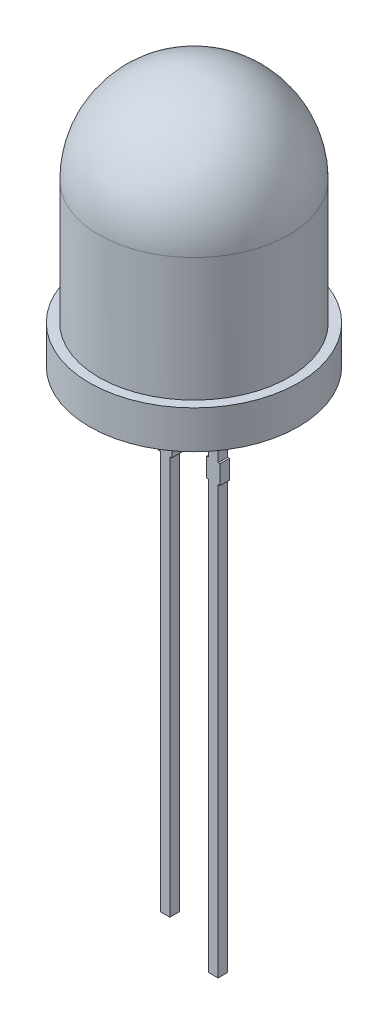
from build123d import *

# Parameters (mm, degrees)
SKETCH2_R          = 5.5
EXTRUDE2_DEPTH     = 2
SKETCH3_3_W        = 0.5
SKETCH3_3_H        = 3.5
SKETCH3_3_H_2      = 1
SKETCH3_3_H_3      = 21
SKETCH3_3_W_2      = 0.1
SKETCH3_3_H_4      = 22.5
EXTRUDE4_DEPTH     = 0.25
CUT_EXTRUDE1_DEPTH = 0.01


with BuildPart() as part:
    # Sketch2 → Extrude2 (new body)
    with BuildSketch(Plane(origin=(0, 0, 0), x_dir=(1, 0, 0), z_dir=(0, 1, 0))):
        with Locations(Location((0, 0, 0), (0, 0, 270))):  # turned: the seam where the file's is
            Circle(SKETCH2_R)
    extrude(amount=EXTRUDE2_DEPTH)

    # Sketch3 → Revolve1 (revolve)
    with BuildSketch(Plane.XY, mode=Mode.PRIVATE) as revolve1_sk:
        with BuildLine():
            Line((0, 13.5), (0, 2))
            Line((0, 2), (5, 2))
            Line((5, 2), (5, 8.5))
            ThreePointArc((5, 8.5), (3.535533906, 12.035533906), (0, 13.5))
        make_face()
    revolve(revolve1_sk.sketch.rotate(Axis((0, 2, 0), (0, 1, 0)), 180), axis=Axis((0, 2, 0), (0, 1, 0)))  # turned: the seam where the file's is

    # Sketch3_3 → Extrude4 (add, symmetric)
    with BuildSketch(Plane.XY):
        with Locations((-1.27, -1.75)):
            Rectangle(SKETCH3_3_W, SKETCH3_3_H)
        with Locations((-1.27, -4)):
            Rectangle(SKETCH3_3_W, SKETCH3_3_H_2)
        with Locations((-1.27, -15)):
            Rectangle(SKETCH3_3_W, SKETCH3_3_H_3)
        with Locations((-0.97, -4)):
            Rectangle(SKETCH3_3_W_2, SKETCH3_3_H_2)
        with Locations((-1.57, -4)):
            Rectangle(SKETCH3_3_W_2, SKETCH3_3_H_2)
        with Locations((1.27, -1.75)):
            Rectangle(SKETCH3_3_W, SKETCH3_3_H)
        with Locations((1.27, -4)):
            Rectangle(SKETCH3_3_W, SKETCH3_3_H_2)
        with Locations((0.97, -4)):
            Rectangle(SKETCH3_3_W_2, SKETCH3_3_H_2)
        with Locations((1.57, -4)):
            Rectangle(SKETCH3_3_W_2, SKETCH3_3_H_2)
        with Locations((1.27, -15.75)):
            Rectangle(SKETCH3_3_W, SKETCH3_3_H_4)
    extrude(amount=EXTRUDE4_DEPTH, both=True)

    # Sketch5 → Cut-Extrude1 (cut)
    with BuildSketch(Plane.XZ):
        Polygon((-0.506420788, 0.019460325), (-0.528175596, -0.053616598), (-0.544431606, -0.053616598), (-0.556661173, -0.002685107), (-0.570543384, -0.053616598), (-0.58670925, -0.053616598), (-0.608343865, 0.019460325), (-0.589593865, 0.019460325), (-0.578626317, -0.033364194), (-0.565555404, 0.019460325), (-0.547376317, 0.019460325), (-0.535958048, -0.033364194), (-0.525260933, 0.019460325), align=None)
        Polygon((-0.406420788, 0.019460325), (-0.428175596, -0.053616598), (-0.444431606, -0.053616598), (-0.456661173, -0.002685107), (-0.470543384, -0.053616598), (-0.48670925, -0.053616598), (-0.508343865, 0.019460325), (-0.489593865, 0.019460325), (-0.478626317, -0.033364194), (-0.465555404, 0.019460325), (-0.447376317, 0.019460325), (-0.435958048, -0.033364194), (-0.425260933, 0.019460325), align=None)
        Polygon((-0.306420788, 0.019460325), (-0.328175596, -0.053616598), (-0.344431606, -0.053616598), (-0.356661173, -0.002685107), (-0.370543384, -0.053616598), (-0.38670925, -0.053616598), (-0.408343865, 0.019460325), (-0.389593865, 0.019460325), (-0.378626317, -0.033364194), (-0.365555404, 0.019460325), (-0.347376317, 0.019460325), (-0.335958048, -0.033364194), (-0.325260933, 0.019460325), align=None)
        with BuildLine():
            add(Edge.make_bspline(
                [(-0.266036173, -0.041116598), (-0.266085656, -0.041823455), (-0.266188443, -0.043291736), (-0.266956737, -0.045436115), (-0.26809552, -0.047545152), (-0.269733004, -0.049465295), (-0.271830584, -0.051145185), (-0.274341711, -0.052524917), (-0.277281997, -0.053461887), (-0.27938031, -0.053564061), (-0.28045925, -0.053616598)],
                knots=[0, 0, 0, 0, 0.803957419, 1.669978378, 2.568830098, 3.52434643, 4.522321038, 5.61514242, 6.773720829, 8, 8, 8, 8], degree=3))
            add(Edge.make_bspline(
                [(-0.28045925, -0.053616598), (-0.281296472, -0.053573063), (-0.282975241, -0.053485769), (-0.285370285, -0.052698164), (-0.287544342, -0.051535025), (-0.289416473, -0.049985848), (-0.290875306, -0.048076689), (-0.292084891, -0.045979976), (-0.292823926, -0.043607544), (-0.292913819, -0.04195285), (-0.29295925, -0.041116598)],
                knots=[0, 0, 0, 0, 1.021956945, 2.049191568, 3.052757421, 4.027239216, 4.995768388, 5.977850542, 6.978043055, 8, 8, 8, 8], degree=3))
            add(Edge.make_bspline(
                [(-0.29295925, -0.041116598), (-0.292915955, -0.040279427), (-0.292830784, -0.038632504), (-0.29206897, -0.036286655), (-0.290922794, -0.034177935), (-0.289422618, -0.032310803), (-0.287583678, -0.030711261), (-0.285368094, -0.029583562), (-0.282982384, -0.028736766), (-0.281297833, -0.028656537), (-0.28045925, -0.028616598)],
                knots=[0, 0, 0, 0, 1.02256761, 2.011643391, 2.988402578, 3.947919371, 4.930894396, 5.945859716, 6.97743239, 8, 8, 8, 8], degree=3))
            add(Edge.make_bspline(
                [(-0.28045925, -0.028616598), (-0.27940861, -0.028666681), (-0.277333943, -0.02876558), (-0.274437579, -0.029772394), (-0.271836687, -0.031063254), (-0.269763337, -0.032822811), (-0.268092381, -0.034726769), (-0.266921011, -0.036806405), (-0.266193696, -0.038956342), (-0.266087663, -0.040410466), (-0.266036173, -0.041116598)],
                knots=[0, 0, 0, 0, 1.193718436, 2.357200027, 3.46616707, 4.488721408, 5.436751473, 6.342315378, 7.195018269, 8, 8, 8, 8], degree=3))
        make_face()
        with BuildLine():
            add(Edge.make_bspline(
                [(-0.205699634, -0.055539675), (-0.207413904, -0.055517214), (-0.210729509, -0.055473772), (-0.215534072, -0.054959005), (-0.220015017, -0.054249645), (-0.224155597, -0.053156817), (-0.227960445, -0.051781664), (-0.231435716, -0.050102824), (-0.23465295, -0.048236117), (-0.237509559, -0.046012892), (-0.240068523, -0.043595864), (-0.242288172, -0.040931811), (-0.244223661, -0.038089814), (-0.245813751, -0.034963223), (-0.247054364, -0.03152243), (-0.247933828, -0.027698355), (-0.248545141, -0.023486793), (-0.248665752, -0.020535937), (-0.248728481, -0.019001213)],
                knots=[0, 0, 0, 0, 1.28338536, 2.482222902, 3.615641418, 4.678302996, 5.684574369, 6.640891817, 7.565949061, 8.464746586, 9.345581526, 10.197575617, 11.056903422, 11.91580542, 12.817603529, 13.789275343, 14.850214295, 16, 16, 16, 16], degree=3))
            Line((-0.248728481, -0.019001213), (-0.229708048, -0.019001213))
            add(Edge.make_bspline(
                [(-0.229708048, -0.019001213), (-0.229585927, -0.020225629), (-0.229355557, -0.022535394), (-0.228758836, -0.025751798), (-0.228006821, -0.028526917), (-0.226988752, -0.030853846), (-0.225830833, -0.032838935), (-0.224538806, -0.034571565), (-0.223183301, -0.036133139), (-0.221201376, -0.037905106), (-0.218429923, -0.039669232), (-0.214715728, -0.04113183), (-0.210622007, -0.041933485), (-0.207776414, -0.042028736), (-0.206300596, -0.042078136)],
                knots=[0, 0, 0, 0, 1.193967772, 2.252326225, 3.172507138, 3.978093684, 4.710151129, 5.398551009, 6.073569162, 6.713873795, 7.973381569, 9.239028936, 10.568070259, 12, 12, 12, 12], degree=3))
            add(Edge.make_bspline(
                [(-0.206300596, -0.042078136), (-0.204733758, -0.042034008), (-0.201766774, -0.041950448), (-0.197585022, -0.041121958), (-0.193942915, -0.03983134), (-0.190876938, -0.038012174), (-0.188433126, -0.035764646), (-0.186594826, -0.033159475), (-0.185449349, -0.030137339), (-0.18532909, -0.027985728), (-0.185266942, -0.026873809)],
                knots=[0, 0, 0, 0, 1.292881893, 2.448216373, 3.505729005, 4.47062867, 5.372299035, 6.228402631, 7.084466243, 8, 8, 8, 8], degree=3))
            add(Edge.make_bspline(
                [(-0.185266942, -0.026873809), (-0.185320446, -0.025754265), (-0.185419768, -0.023676007), (-0.186258265, -0.021231036), (-0.187306338, -0.019609152), (-0.188296806, -0.018475245), (-0.189528629, -0.017403138), (-0.191011434, -0.016421789), (-0.192760546, -0.015488895), (-0.194759724, -0.014556991), (-0.197065514, -0.013694137), (-0.199656508, -0.012857154), (-0.202562466, -0.012032856), (-0.205771438, -0.011098723), (-0.209355364, -0.010265899), (-0.211849921, -0.009667841), (-0.213151558, -0.00935578)],
                knots=[0, 0, 0, 0, 1.308217091, 2.428499093, 2.971811445, 3.562083625, 4.185450824, 4.878313926, 5.639298351, 6.505129032, 7.459166185, 8.51991211, 9.692741175, 10.996059842, 12.432571982, 14, 14, 14, 14], degree=3))
            add(Edge.make_bspline(
                [(-0.213151558, -0.00935578), (-0.214435652, -0.009043397), (-0.216924255, -0.008437991), (-0.220539382, -0.007416015), (-0.223901847, -0.006275541), (-0.227054373, -0.005086069), (-0.229945155, -0.003760707), (-0.232596235, -0.002330726), (-0.23497175, -0.000763156), (-0.237098815, 0.000887788), (-0.238955133, 0.002678744), (-0.240558534, 0.004613008), (-0.241916173, 0.006686454), (-0.243014498, 0.008916691), (-0.243851235, 0.011299184), (-0.244452404, 0.013846914), (-0.244816946, 0.01655512), (-0.244860201, 0.018417508), (-0.244882327, 0.019370181)],
                knots=[0, 0, 0, 0, 1.350138021, 2.616595417, 3.836558268, 4.976793827, 6.057431512, 7.083186274, 8.051004732, 8.961973241, 9.830394181, 10.680720399, 11.523687559, 12.356594861, 13.21427804, 14.097880016, 15.027001965, 16, 16, 16, 16], degree=3))
            add(Edge.make_bspline(
                [(-0.244882327, 0.019370181), (-0.244842894, 0.020403359), (-0.244765132, 0.022440775), (-0.244292617, 0.025433959), (-0.243428398, 0.028292297), (-0.242257665, 0.031022793), (-0.240791194, 0.03360767), (-0.239018254, 0.036001213), (-0.237013216, 0.038224301), (-0.234733455, 0.040255227), (-0.232210161, 0.042074969), (-0.229465506, 0.043717042), (-0.226465678, 0.04509047), (-0.2232523, 0.046263017), (-0.219835071, 0.047190291), (-0.216247044, 0.047845846), (-0.212509743, 0.048247056), (-0.20996748, 0.048286445), (-0.208674394, 0.048306479)],
                knots=[0, 0, 0, 0, 0.957814223, 1.888799201, 2.799332819, 3.718439235, 4.637311203, 5.547134667, 6.473851604, 7.407471124, 8.371205588, 9.353539842, 10.366965553, 11.424217362, 12.520959394, 13.644407811, 14.801862002, 16, 16, 16, 16], degree=3))
            add(Edge.make_bspline(
                [(-0.208674394, 0.048306479), (-0.207221537, 0.048272033), (-0.204370695, 0.048204442), (-0.200175593, 0.047838445), (-0.196177011, 0.047090419), (-0.192344082, 0.046144703), (-0.188725247, 0.044919246), (-0.185329558, 0.04344609), (-0.182198622, 0.04170499), (-0.179347222, 0.039711078), (-0.176751944, 0.037560857), (-0.174478032, 0.035214514), (-0.172579283, 0.032668992), (-0.170980851, 0.029945369), (-0.169677682, 0.026929737), (-0.16877781, 0.023517117), (-0.168177637, 0.019700046), (-0.168034324, 0.017018758), (-0.16795925, 0.015614171)],
                knots=[0, 0, 0, 0, 1.186950675, 2.32907279, 3.434719709, 4.506181443, 5.551366779, 6.551492465, 7.525684865, 8.472032948, 9.389619293, 10.274870494, 11.133875947, 11.977154569, 12.849419986, 13.808029842, 14.851741326, 16, 16, 16, 16], degree=3))
            Line((-0.16795925, 0.015614171), (-0.187039779, 0.015614171))
            add(Edge.make_bspline(
                [(-0.187039779, 0.015614171), (-0.187232871, 0.017125501), (-0.187599619, 0.019996024), (-0.188861191, 0.023979238), (-0.190713496, 0.027347869), (-0.193103476, 0.030149068), (-0.196101258, 0.032286749), (-0.199645926, 0.033796791), (-0.203722488, 0.034693955), (-0.20661635, 0.034793009), (-0.208133529, 0.034844941)],
                knots=[0, 0, 0, 0, 1.138878594, 2.163113395, 3.106118689, 3.999005743, 4.895818561, 5.835958478, 6.865448045, 8, 8, 8, 8], degree=3))
            add(Edge.make_bspline(
                [(-0.208133529, 0.034844941), (-0.20945783, 0.034797138), (-0.211964488, 0.034706656), (-0.215512457, 0.034080945), (-0.21855812, 0.032889723), (-0.221152614, 0.031304392), (-0.223196337, 0.029211124), (-0.224642236, 0.026645315), (-0.225533078, 0.023644779), (-0.225610837, 0.021490115), (-0.225651558, 0.020361768)],
                knots=[0, 0, 0, 0, 1.229005574, 2.326279772, 3.32381644, 4.246881527, 5.127569263, 6.005949281, 6.955762047, 8, 8, 8, 8], degree=3))
            add(Edge.make_bspline(
                [(-0.225651558, 0.020361768), (-0.225611058, 0.019336675), (-0.225536848, 0.017458307), (-0.22487074, 0.014864265), (-0.223590396, 0.012819751), (-0.221811986, 0.011102525), (-0.219286531, 0.009750291), (-0.21602758, 0.008398008), (-0.21185704, 0.007102047), (-0.2087494, 0.006349683), (-0.207051798, 0.005938691)],
                knots=[0, 0, 0, 0, 0.944171751, 1.730091105, 2.434406385, 3.13926556, 3.982880664, 5.054072901, 6.39073578, 8, 8, 8, 8], degree=3))
            add(Edge.make_bspline(
                [(-0.207051798, 0.005938691), (-0.20501489, 0.005503457), (-0.201157992, 0.00467934), (-0.195747453, 0.003275247), (-0.190958629, 0.00194205), (-0.188008003, 0.000961531), (-0.186619106, 0.000499989)],
                knots=[0, 0, 0, 0, 1.181242773, 2.236690395, 3.169987357, 4, 4, 4, 4], degree=3))
            add(Edge.make_bspline(
                [(-0.186619106, 0.000499989), (-0.185092112, -0.000119134), (-0.1821929, -0.001294626), (-0.178226842, -0.003494467), (-0.174767079, -0.006033734), (-0.17177866, -0.009015207), (-0.169279699, -0.012455393), (-0.167450737, -0.016334973), (-0.166248488, -0.020573761), (-0.166107972, -0.023530227), (-0.166036173, -0.025040877)],
                knots=[0, 0, 0, 0, 1.12559323, 2.137097481, 3.091563588, 4.050170991, 5.011659374, 5.982488114, 6.969123197, 8, 8, 8, 8], degree=3))
            add(Edge.make_bspline(
                [(-0.166036173, -0.025040877), (-0.166068169, -0.026075455), (-0.166131371, -0.028119026), (-0.166720117, -0.031135957), (-0.167554962, -0.034090624), (-0.1688592, -0.036907223), (-0.170388663, -0.039630207), (-0.172337128, -0.042121827), (-0.174477967, -0.044514692), (-0.176965526, -0.046684512), (-0.179737712, -0.048623691), (-0.182772565, -0.050397177), (-0.186106411, -0.051900792), (-0.18967382, -0.053228794), (-0.193449522, -0.054287002), (-0.197406569, -0.054982943), (-0.201501352, -0.055459616), (-0.204285966, -0.055512717), (-0.205699634, -0.055539675)],
                knots=[0, 0, 0, 0, 0.891235748, 1.760430872, 2.64325458, 3.532604557, 4.430471646, 5.330579775, 6.253890478, 7.196515965, 8.169562172, 9.16815398, 10.223350337, 11.319304113, 12.44891929, 13.599348363, 14.781258036, 16, 16, 16, 16], degree=3))
        make_face()
        with BuildLine():
            add(Edge.make_bspline(
                [(-0.108343865, -0.04592429), (-0.108793127, -0.046689894), (-0.10967458, -0.048192013), (-0.111358114, -0.050182775), (-0.113334947, -0.051846607), (-0.115586627, -0.053210659), (-0.118109577, -0.054264129), (-0.120908325, -0.055010589), (-0.123974356, -0.055459971), (-0.126110722, -0.05551253), (-0.127214058, -0.055539675)],
                knots=[0, 0, 0, 0, 0.951672298, 1.867185576, 2.782698853, 3.71392514, 4.682455292, 5.707525699, 6.816041397, 8, 8, 8, 8], degree=3))
            add(Edge.make_bspline(
                [(-0.127214058, -0.055539675), (-0.128236196, -0.055511888), (-0.130224808, -0.055457827), (-0.133114314, -0.055175895), (-0.135797603, -0.054628112), (-0.138293148, -0.053886751), (-0.140569775, -0.052884959), (-0.142682274, -0.051712592), (-0.144576932, -0.050293003), (-0.146275656, -0.048660137), (-0.147756606, -0.046803136), (-0.149048523, -0.044744405), (-0.150183255, -0.042482308), (-0.15102863, -0.039965804), (-0.151721243, -0.037253778), (-0.152230537, -0.034331558), (-0.152533213, -0.031197187), (-0.15256055, -0.029037967), (-0.152574634, -0.027925492)],
                knots=[0, 0, 0, 0, 1.141517227, 2.220869849, 3.236285704, 4.194941571, 5.121491616, 6.007825957, 6.886792942, 7.75675051, 8.631724762, 9.531432414, 10.466647329, 11.449839378, 12.488631973, 13.589891555, 14.758261493, 16, 16, 16, 16], degree=3))
            Line((-0.152574634, -0.027925492), (-0.152574634, 0.019460325))
            Line((-0.152574634, 0.019460325), (-0.133343865, 0.019460325))
            Line((-0.133343865, 0.019460325), (-0.133343865, -0.027835348))
            add(Edge.make_bspline(
                [(-0.133343865, -0.027835348), (-0.13331403, -0.029158134), (-0.133259849, -0.031560291), (-0.132914015, -0.0348159), (-0.132254722, -0.037351172), (-0.131318555, -0.039265756), (-0.130026042, -0.040573786), (-0.128511907, -0.041463428), (-0.126736055, -0.041983357), (-0.125474862, -0.042045426), (-0.124810211, -0.042078136)],
                knots=[0, 0, 0, 0, 1.670420621, 3.033453265, 4.122593961, 4.965404288, 5.689746319, 6.409770491, 7.161946514, 8, 8, 8, 8], degree=3))
            add(Edge.make_bspline(
                [(-0.124810211, -0.042078136), (-0.124066395, -0.042051498), (-0.122573106, -0.041998019), (-0.120369487, -0.041490006), (-0.118213984, -0.040695061), (-0.116097024, -0.039620721), (-0.114077169, -0.038167492), (-0.112090527, -0.036453659), (-0.110150081, -0.034419132), (-0.108961563, -0.032894539), (-0.108343865, -0.032102175)],
                knots=[0, 0, 0, 0, 0.891993808, 1.790772165, 2.70010969, 3.646775564, 4.631044069, 5.679839113, 6.794162298, 8, 8, 8, 8], degree=3))
            Line((-0.108343865, -0.032102175), (-0.108343865, 0.019460325))
            Line((-0.108343865, 0.019460325), (-0.089113096, 0.019460325))
            Line((-0.089113096, 0.019460325), (-0.089113096, -0.053616598))
            Line((-0.089113096, -0.053616598), (-0.108343865, -0.053616598))
            Line((-0.108343865, -0.053616598), (-0.108343865, -0.04592429))
        make_face()
        with BuildLine():
            add(Edge.make_bspline(
                [(-0.054497711, 0.011768018), (-0.054099622, 0.012533036), (-0.053321752, 0.014027889), (-0.051791918, 0.016000545), (-0.050032757, 0.017678478), (-0.048021413, 0.019044479), (-0.045761488, 0.020110251), (-0.04325708, 0.020843707), (-0.040512459, 0.02130841), (-0.038604292, 0.021357724), (-0.037610692, 0.021383402)],
                knots=[0, 0, 0, 0, 1.00143585, 1.95681651, 2.888024611, 3.818649522, 4.772323889, 5.782194879, 6.845168342, 8, 8, 8, 8], degree=3))
            add(Edge.make_bspline(
                [(-0.037610692, 0.021383402), (-0.036508463, 0.021355785), (-0.034369978, 0.021302204), (-0.031261109, 0.021019273), (-0.028369096, 0.020469665), (-0.025671487, 0.019737325), (-0.023209692, 0.018725052), (-0.020923544, 0.017576939), (-0.01889934, 0.016127631), (-0.017051381, 0.014518538), (-0.01544924, 0.01265772), (-0.014059199, 0.010599945), (-0.01287747, 0.008322359), (-0.011924081, 0.005819453), (-0.011177334, 0.003102107), (-0.010632173, 0.000178269), (-0.010347908, -0.002959955), (-0.010294475, -0.0051185), (-0.010266942, -0.00623078)],
                knots=[0, 0, 0, 0, 1.186832343, 2.3026268, 3.355761513, 4.352522852, 5.305579363, 6.217046986, 7.099481147, 7.977887867, 8.849185092, 9.734381594, 10.645849217, 11.604985507, 12.612131568, 13.675865719, 14.802392456, 16, 16, 16, 16], degree=3))
            Line((-0.010266942, -0.00623078), (-0.010266942, -0.053616598))
            Line((-0.010266942, -0.053616598), (-0.029497711, -0.053616598))
            Line((-0.029497711, -0.053616598), (-0.029497711, -0.006320925))
            add(Edge.make_bspline(
                [(-0.029497711, -0.006320925), (-0.029522687, -0.005087594), (-0.02956878, -0.002811442), (-0.029985974, 0.000307414), (-0.030741901, 0.002834703), (-0.031847519, 0.004805592), (-0.033336299, 0.006288627), (-0.035256371, 0.00723412), (-0.037521834, 0.007856266), (-0.039168328, 0.007899079), (-0.040044586, 0.007921864)],
                knots=[0, 0, 0, 0, 1.441015903, 2.659442997, 3.666423338, 4.505664336, 5.275500286, 6.081849636, 6.979166905, 8, 8, 8, 8], degree=3))
            add(Edge.make_bspline(
                [(-0.040044586, 0.007921864), (-0.040617762, 0.007889677), (-0.041778891, 0.007824475), (-0.04353866, 0.007381148), (-0.04529625, 0.006615422), (-0.047096788, 0.005571192), (-0.048915348, 0.004237942), (-0.05079957, 0.002646494), (-0.052644407, 0.00069473), (-0.05386255, -0.000717023), (-0.054497711, -0.001453136)],
                knots=[0, 0, 0, 0, 0.774464777, 1.568897174, 2.436202086, 3.357883609, 4.375901529, 5.479906668, 6.685976861, 8, 8, 8, 8], degree=3))
            Line((-0.054497711, -0.001453136), (-0.054497711, -0.053616598))
            Line((-0.054497711, -0.053616598), (-0.073728481, -0.053616598))
            Line((-0.073728481, -0.053616598), (-0.073728481, 0.019460325))
            Line((-0.073728481, 0.019460325), (-0.054497711, 0.019460325))
            Line((-0.054497711, 0.019460325), (-0.054497711, 0.011768018))
        make_face()
        Polygon((0.074348442, -0.053616598), (0.00704075, -0.053616598), (0.00704075, 0.046383402), (0.026271519, 0.046383402), (0.026271519, -0.040155059), (0.074348442, -0.040155059), align=None)
        Polygon((0.164733058, -0.053616598), (0.085886904, -0.053616598), (0.085886904, 0.046383402), (0.162809981, 0.046383402), (0.162809981, 0.032921864), (0.105117673, 0.032921864), (0.105117673, 0.00407571), (0.158963827, 0.00407571), (0.158963827, -0.009385829), (0.105117673, -0.009385829), (0.105117673, -0.040155059), (0.164733058, -0.040155059), align=None)
        with BuildLine():
            add(Edge.make_bspline(
                [(0.266656135, -0.003075732), (0.266618646, -0.005120721), (0.266546049, -0.009080827), (0.265904683, -0.014830164), (0.264862265, -0.020177856), (0.263436579, -0.025153874), (0.261535533, -0.029719179), (0.259206877, -0.033884885), (0.256505818, -0.037695027), (0.253298155, -0.041030571), (0.249746035, -0.044056166), (0.245700923, -0.046586247), (0.241298634, -0.048809296), (0.236441969, -0.050572159), (0.231178236, -0.051938439), (0.225501844, -0.052931571), (0.219411675, -0.0534881), (0.215214945, -0.053572873), (0.213050366, -0.053616598)],
                knots=[0, 0, 0, 0, 1.161219646, 2.24869368, 3.280708715, 4.252829228, 5.183621711, 6.082630713, 6.958888302, 7.828118733, 8.704376322, 9.602322718, 10.530939534, 11.501077163, 12.530454616, 13.6163204, 14.770551419, 16, 16, 16, 16], degree=3))
            Line((0.213050366, -0.053616598), (0.180117673, -0.053616598))
            Line((0.180117673, -0.053616598), (0.180117673, 0.046383402))
            Line((0.180117673, 0.046383402), (0.213050366, 0.046383402))
            add(Edge.make_bspline(
                [(0.213050366, 0.046383402), (0.215215493, 0.04635696), (0.219414531, 0.046305679), (0.225497048, 0.045678505), (0.231176515, 0.04473804), (0.236443162, 0.043403094), (0.241278815, 0.041650023), (0.245718629, 0.039550018), (0.249720138, 0.037022792), (0.253319783, 0.034105607), (0.256482658, 0.030795139), (0.259209392, 0.027078428), (0.261533984, 0.022998187), (0.263437788, 0.018523911), (0.264853647, 0.01365497), (0.265912253, 0.008420422), (0.266542534, 0.002799022), (0.266617561, -0.001080923), (0.266656135, -0.003075732)],
                knots=[0, 0, 0, 0, 1.24197401, 2.408678741, 3.504780762, 4.5433438, 5.521527764, 6.452152268, 7.356290842, 8.230615943, 9.104657617, 9.976030571, 10.869306848, 11.793823342, 12.759447772, 13.773938722, 14.855507726, 16, 16, 16, 16], degree=3))
        make_face()
        with BuildLine():
            add(Edge.make_bspline(
                [(0.247425366, -0.003045684), (0.24741515, -0.001662572), (0.24739528, 0.00102782), (0.247036986, 0.004947453), (0.246548371, 0.008654415), (0.245820829, 0.012136482), (0.244932596, 0.015400543), (0.24367184, 0.01835705), (0.242211253, 0.021073727), (0.24041577, 0.023485751), (0.238342856, 0.025678614), (0.235888665, 0.02755978), (0.233087724, 0.029205368), (0.229902003, 0.030547762), (0.226329233, 0.031631326), (0.222323869, 0.03240774), (0.217877783, 0.032842005), (0.214764074, 0.032894494), (0.21314051, 0.032921864)],
                knots=[0, 0, 0, 0, 1.149495408, 2.235966294, 3.270011624, 4.256484947, 5.192194903, 6.076854796, 6.922927111, 7.750728226, 8.569431422, 9.423985878, 10.312361613, 11.263690782, 12.291074984, 13.411453686, 14.650268675, 16, 16, 16, 16], degree=3))
            Line((0.21314051, 0.032921864), (0.199348442, 0.032921864))
            Line((0.199348442, 0.032921864), (0.199348442, -0.040155059))
            Line((0.199348442, -0.040155059), (0.21314051, -0.040155059))
            add(Edge.make_bspline(
                [(0.21314051, -0.040155059), (0.214774479, -0.040131824), (0.217899994, -0.04008738), (0.222352198, -0.039602001), (0.226349115, -0.038837105), (0.229903191, -0.037765098), (0.233043295, -0.036362975), (0.235820941, -0.034701086), (0.238302465, -0.032812058), (0.240388132, -0.030575422), (0.242181275, -0.02807918), (0.243687652, -0.025303748), (0.244882177, -0.022227027), (0.245838266, -0.018886176), (0.246545808, -0.015274778), (0.247041361, -0.011409648), (0.247393355, -0.007308945), (0.24741453, -0.004488782), (0.247425366, -0.003045684)],
                knots=[0, 0, 0, 0, 1.33477961, 2.553215293, 3.654392007, 4.656342135, 5.579650195, 6.456971844, 7.296880229, 8.119053426, 8.945898676, 9.802940951, 10.692095258, 11.637628976, 12.639278173, 13.696155562, 14.821106832, 16, 16, 16, 16], degree=3))
        make_face(mode=Mode.SUBTRACT)
        with BuildLine():
            add(Edge.make_bspline(
                [(0.312809981, -0.041116598), (0.312760498, -0.041823455), (0.312657711, -0.043291736), (0.311889417, -0.045436115), (0.310750634, -0.047545152), (0.30911315, -0.049465295), (0.30701557, -0.051145185), (0.304504443, -0.052524917), (0.301564157, -0.053461887), (0.299465844, -0.053564061), (0.298386904, -0.053616598)],
                knots=[0, 0, 0, 0, 0.803957419, 1.669978378, 2.568830098, 3.52434643, 4.522321038, 5.61514242, 6.773720829, 8, 8, 8, 8], degree=3))
            add(Edge.make_bspline(
                [(0.298386904, -0.053616598), (0.297549682, -0.053573063), (0.295870913, -0.053485769), (0.293475868, -0.052698164), (0.291301812, -0.051535025), (0.289429681, -0.049985848), (0.287970848, -0.048076689), (0.286761263, -0.045979976), (0.286022228, -0.043607544), (0.285932335, -0.04195285), (0.285886904, -0.041116598)],
                knots=[0, 0, 0, 0, 1.021956945, 2.049191568, 3.052757421, 4.027239216, 4.995768388, 5.977850542, 6.978043055, 8, 8, 8, 8], degree=3))
            add(Edge.make_bspline(
                [(0.285886904, -0.041116598), (0.285930199, -0.040279427), (0.28601537, -0.038632504), (0.286777184, -0.036286655), (0.28792336, -0.034177935), (0.289423536, -0.032310803), (0.291262476, -0.030711261), (0.293478059, -0.029583562), (0.29586377, -0.028736766), (0.297548321, -0.028656537), (0.298386904, -0.028616598)],
                knots=[0, 0, 0, 0, 1.02256761, 2.011643391, 2.988402578, 3.947919371, 4.930894396, 5.945859716, 6.97743239, 8, 8, 8, 8], degree=3))
            add(Edge.make_bspline(
                [(0.298386904, -0.028616598), (0.299437544, -0.028666681), (0.30151221, -0.02876558), (0.304408575, -0.029772394), (0.307009467, -0.031063254), (0.309082817, -0.032822811), (0.310753773, -0.034726769), (0.311925142, -0.036806405), (0.312652458, -0.038956342), (0.312758491, -0.040410466), (0.312809981, -0.041116598)],
                knots=[0, 0, 0, 0, 1.193718436, 2.357200027, 3.46616707, 4.488721408, 5.436751473, 6.342315378, 7.195018269, 8, 8, 8, 8], degree=3))
        make_face()
        with BuildLine():
            add(Edge.make_bspline(
                [(0.363260702, -0.055539675), (0.361976329, -0.055519015), (0.359456904, -0.055478488), (0.355775337, -0.054917025), (0.352237155, -0.054179201), (0.348904218, -0.05301391), (0.345767108, -0.051592802), (0.342883354, -0.049808913), (0.340197743, -0.047785272), (0.337789234, -0.04541288), (0.335615008, -0.042784841), (0.333682325, -0.039889887), (0.332034187, -0.0367216), (0.330648683, -0.033301087), (0.329523207, -0.029626008), (0.328768969, -0.02567637), (0.328263492, -0.021468245), (0.328218042, -0.018572124), (0.328194596, -0.017078136)],
                knots=[0, 0, 0, 0, 1.047336758, 2.054456287, 3.03439317, 3.993646679, 4.930156219, 5.840202366, 6.755960155, 7.669488798, 8.592807151, 9.536144313, 10.505277466, 11.502793093, 12.545139458, 13.637098113, 14.781077921, 16, 16, 16, 16], degree=3))
            add(Edge.make_bspline(
                [(0.328194596, -0.017078136), (0.328219048, -0.015614314), (0.328266754, -0.012758426), (0.328765423, -0.008598906), (0.329536554, -0.004677006), (0.330615617, -0.000992117), (0.332005684, 0.002444072), (0.333646519, 0.005629967), (0.335563986, 0.008546483), (0.337716606, 0.011209057), (0.340177983, 0.013542111), (0.342821615, 0.015657392), (0.34576104, 0.017384307), (0.348901012, 0.018834217), (0.352242294, 0.019982262), (0.355770526, 0.020771404), (0.359457596, 0.021319311), (0.361976563, 0.021361761), (0.363260702, 0.021383402)],
                knots=[0, 0, 0, 0, 1.194867585, 2.331162469, 3.415519797, 4.45592294, 5.461402785, 6.438161706, 7.377349552, 8.307339102, 9.227093374, 10.141741913, 11.066139606, 12.003009567, 12.962632249, 13.944753045, 14.952260169, 16, 16, 16, 16], degree=3))
            add(Edge.make_bspline(
                [(0.363260702, 0.021383402), (0.364313242, 0.021358383), (0.366403392, 0.0213087), (0.369486443, 0.020971238), (0.372492548, 0.020434056), (0.375387274, 0.019658661), (0.378154943, 0.018659779), (0.380766287, 0.017502367), (0.383195711, 0.016141322), (0.385420401, 0.014580149), (0.387435315, 0.012830021), (0.389258541, 0.010927893), (0.390850574, 0.008852718), (0.392236627, 0.006583958), (0.393388514, 0.004053307), (0.394313163, 0.001178114), (0.39506913, -0.002045847), (0.395354058, -0.004344059), (0.395502289, -0.005539675)],
                knots=[0, 0, 0, 0, 1.080765488, 2.146200892, 3.181163785, 4.214080283, 5.219383685, 6.200022783, 7.144110219, 8.074369293, 8.985844923, 9.880687245, 10.775588676, 11.666402291, 12.605320916, 13.623381954, 14.763593765, 16, 16, 16, 16], degree=3))
            Line((0.395502289, -0.005539675), (0.376361664, -0.005539675))
            add(Edge.make_bspline(
                [(0.376361664, -0.005539675), (0.376270505, -0.00437181), (0.376100713, -0.00219655), (0.375294532, 0.00075941), (0.374098559, 0.003195865), (0.37238484, 0.005004765), (0.370371542, 0.00630781), (0.368152077, 0.007240549), (0.365715335, 0.007835508), (0.364015444, 0.00789252), (0.36314051, 0.007921864)],
                knots=[0, 0, 0, 0, 1.312413462, 2.444497233, 3.420095611, 4.326995713, 5.203269489, 6.094987921, 7.019489993, 8, 8, 8, 8], degree=3))
            add(Edge.make_bspline(
                [(0.36314051, 0.007921864), (0.362119768, 0.00787408), (0.360119394, 0.007780438), (0.357754895, 0.006910738), (0.356000888, 0.005962393), (0.354770183, 0.004970251), (0.353565525, 0.003791214), (0.352394777, 0.00241307), (0.351294233, 0.000803957), (0.350351931, -0.001062996), (0.349513135, -0.003158258), (0.348754994, -0.00547074), (0.34815823, -0.008023256), (0.347748536, -0.01082769), (0.347471478, -0.013867482), (0.347441055, -0.015985728), (0.347425366, -0.017078136)],
                knots=[0, 0, 0, 0, 1.294790379, 2.537435469, 3.165661086, 3.829164872, 4.541864701, 5.311227921, 6.128593511, 7.018685834, 7.968657266, 9.00144956, 10.115435461, 11.302621323, 12.608924514, 14, 14, 14, 14], degree=3))
            add(Edge.make_bspline(
                [(0.347425366, -0.017078136), (0.347444447, -0.018180276), (0.347481269, -0.020307157), (0.347711187, -0.023369922), (0.348130392, -0.026192819), (0.348722799, -0.02876555), (0.349474543, -0.031095983), (0.350358909, -0.033176197), (0.351291917, -0.035051939), (0.35270903, -0.03711162), (0.354616, -0.039197957), (0.357245307, -0.040938527), (0.360115889, -0.041930162), (0.362111029, -0.042027771), (0.36314051, -0.042078136)],
                knots=[0, 0, 0, 0, 1.201885478, 2.31936817, 3.346574926, 4.310947528, 5.195171259, 6.012657592, 6.774708936, 7.474495386, 8.733959456, 9.830591055, 10.880597417, 12, 12, 12, 12], degree=3))
            add(Edge.make_bspline(
                [(0.36314051, -0.042078136), (0.364004848, -0.04204579), (0.365681545, -0.041983042), (0.368082216, -0.041433715), (0.370252773, -0.040525872), (0.372176411, -0.039256654), (0.373794658, -0.037600044), (0.374881945, -0.035907723), (0.375558643, -0.034249701), (0.375916205, -0.032645068), (0.376220965, -0.030738654), (0.376331972, -0.029359048), (0.376391712, -0.028616598)],
                knots=[0, 0, 0, 0, 1.210933032, 2.349044084, 3.43171645, 4.495267269, 5.558075774, 6.656937348, 7.293383625, 8.059914447, 8.955920865, 10, 10, 10, 10], degree=3))
            Line((0.376391712, -0.028616598), (0.395502289, -0.028616598))
            add(Edge.make_bspline(
                [(0.395502289, -0.028616598), (0.395341906, -0.02983198), (0.395034909, -0.032158412), (0.39428188, -0.03543601), (0.393348332, -0.038354456), (0.39210941, -0.040884175), (0.390709333, -0.043149588), (0.389098873, -0.045207134), (0.387285626, -0.047106546), (0.385282582, -0.048850303), (0.38306779, -0.050385669), (0.380683463, -0.051740275), (0.378124424, -0.052919347), (0.375393991, -0.053868682), (0.372530441, -0.05461951), (0.369548684, -0.055168255), (0.366441451, -0.055456652), (0.364332936, -0.055511688), (0.363260702, -0.055539675)],
                knots=[0, 0, 0, 0, 1.258051893, 2.408109002, 3.448772144, 4.39629231, 5.292354794, 6.178984465, 7.073688607, 7.985023489, 8.900815369, 9.83580737, 10.797563429, 11.78957876, 12.799817111, 13.834620187, 14.898848121, 16, 16, 16, 16], degree=3))
        make_face()
        with BuildLine():
            add(Edge.make_bspline(
                [(0.435886904, 0.021383402), (0.437281024, 0.021350655), (0.440010065, 0.02128655), (0.444004862, 0.020728046), (0.447803692, 0.019838265), (0.451394625, 0.018565622), (0.454747047, 0.016983708), (0.457831361, 0.015114043), (0.460630216, 0.012973898), (0.463089933, 0.010513662), (0.465301874, 0.007837501), (0.467193618, 0.004907194), (0.468806006, 0.001745911), (0.47010332, -0.001644979), (0.471178634, -0.005224547), (0.47187306, -0.009014278), (0.472346108, -0.012979619), (0.472398608, -0.015694459), (0.472425366, -0.017078136)],
                knots=[0, 0, 0, 0, 1.116475797, 2.185542979, 3.224923316, 4.237598129, 5.231919818, 6.189791294, 7.122353009, 8.047287697, 8.971003188, 9.899169676, 10.835865412, 11.808977354, 12.804367075, 13.825779647, 14.891860981, 16, 16, 16, 16], degree=3))
            add(Edge.make_bspline(
                [(0.472425366, -0.017078136), (0.47239864, -0.018481737), (0.472346571, -0.021216402), (0.471877719, -0.025225154), (0.471144299, -0.029028451), (0.470089457, -0.032631413), (0.468728884, -0.036006535), (0.467111224, -0.039172578), (0.465202125, -0.042116085), (0.463010672, -0.044819263), (0.46053766, -0.047277658), (0.457749652, -0.04942393), (0.45465415, -0.051258628), (0.451303437, -0.052812919), (0.447711856, -0.054054288), (0.443922927, -0.054913045), (0.439957874, -0.055433754), (0.4372607, -0.055503931), (0.435886904, -0.055539675)],
                knots=[0, 0, 0, 0, 1.123562633, 2.189060306, 3.227190231, 4.222034994, 5.190106252, 6.137083223, 7.064741556, 7.99416643, 8.918594733, 9.850645887, 10.803851701, 11.794224938, 12.803704333, 13.840687306, 14.900160981, 16, 16, 16, 16], degree=3))
            add(Edge.make_bspline(
                [(0.435886904, -0.055539675), (0.434613359, -0.055514093), (0.432116821, -0.055463944), (0.428462295, -0.054973695), (0.424994393, -0.054156964), (0.421701467, -0.053057158), (0.418629255, -0.051609411), (0.415779615, -0.04985134), (0.413151934, -0.047793342), (0.410743238, -0.045454472), (0.408603644, -0.042811581), (0.406695814, -0.039920054), (0.405088909, -0.036743013), (0.403685347, -0.033337642), (0.402606293, -0.029640649), (0.401846298, -0.025686655), (0.401340625, -0.021468104), (0.401295037, -0.018572076), (0.401271519, -0.017078136)],
                knots=[0, 0, 0, 0, 1.045185112, 2.048882016, 3.020291938, 3.966880199, 4.893905909, 5.802213808, 6.710261089, 7.629080276, 8.552524605, 9.496788192, 10.46774551, 11.471038078, 12.517063969, 13.623413772, 14.774018743, 16, 16, 16, 16], degree=3))
            add(Edge.make_bspline(
                [(0.401271519, -0.017078136), (0.401299334, -0.015614733), (0.401353389, -0.01277074), (0.401802776, -0.008616364), (0.402593736, -0.004712413), (0.403629254, -0.001022783), (0.404995005, 0.002411292), (0.406598022, 0.005607944), (0.408522465, 0.008508108), (0.410651853, 0.011177163), (0.413064524, 0.013553974), (0.415712221, 0.015635929), (0.418599977, 0.017394664), (0.421708092, 0.018832694), (0.425009173, 0.01997751), (0.428495757, 0.020775482), (0.432133963, 0.021317217), (0.434622856, 0.02136111), (0.435886904, 0.021383402)],
                knots=[0, 0, 0, 0, 1.201848745, 2.335685805, 3.426378622, 4.470561871, 5.478866717, 6.457570667, 7.402245833, 8.332481093, 9.257462806, 10.17745529, 11.093170774, 12.028051071, 12.98550063, 13.957333963, 14.96257992, 16, 16, 16, 16], degree=3))
        make_face()
        with BuildLine():
            add(Edge.make_bspline(
                [(0.435947, -0.042078136), (0.437177973, -0.042004442), (0.439563848, -0.041861609), (0.442945842, -0.040707138), (0.445906678, -0.038781747), (0.447993493, -0.036585373), (0.449398021, -0.034458993), (0.450367211, -0.032607521), (0.451194655, -0.030529473), (0.451926323, -0.028233909), (0.452478655, -0.025717905), (0.452906008, -0.023009892), (0.453138419, -0.020107011), (0.453175455, -0.018110166), (0.453194596, -0.017078136)],
                knots=[0, 0, 0, 0, 1.295059177, 2.510086438, 3.716370727, 4.985576951, 5.670626941, 6.397730367, 7.183741792, 8.025007773, 8.934067091, 9.895485546, 10.912324256, 12, 12, 12, 12], degree=3))
            add(Edge.make_bspline(
                [(0.453194596, -0.017078136), (0.453175857, -0.016046059), (0.453139781, -0.014059103), (0.452904463, -0.011176659), (0.452487381, -0.008516264), (0.451916981, -0.006054433), (0.451191552, -0.003797799), (0.450358097, -0.001723931), (0.449403795, 0.000161533), (0.448276344, 0.001822225), (0.447060324, 0.003284403), (0.445739878, 0.00455846), (0.444305813, 0.005596377), (0.442282581, 0.006724626), (0.439502665, 0.007748583), (0.437149356, 0.007863269), (0.435947, 0.007921864)],
                knots=[0, 0, 0, 0, 1.270965165, 2.446865025, 3.558110639, 4.584301362, 5.555578469, 6.474044422, 7.334617136, 8.152219829, 8.940260781, 9.673084706, 10.405804824, 11.112633012, 12.524781949, 14, 14, 14, 14], degree=3))
            add(Edge.make_bspline(
                [(0.435947, 0.007921864), (0.43495746, 0.007869708), (0.433011727, 0.007767154), (0.430695593, 0.006943129), (0.428987107, 0.005990348), (0.427775731, 0.004990129), (0.426582654, 0.003789575), (0.425411157, 0.002382231), (0.424316959, 0.000749397), (0.423375562, -0.001129681), (0.422491522, -0.003197453), (0.421774831, -0.005503313), (0.421207514, -0.008045735), (0.420789067, -0.010836407), (0.420558059, -0.013879132), (0.420521329, -0.015986011), (0.420502289, -0.017078136)],
                knots=[0, 0, 0, 0, 1.26445895, 2.48630758, 3.107229898, 3.764753363, 4.49086656, 5.274808243, 6.107862949, 7.003443443, 7.964172427, 8.987193514, 10.092654654, 11.299851966, 12.600347358, 14, 14, 14, 14], degree=3))
            add(Edge.make_bspline(
                [(0.420502289, -0.017078136), (0.420521092, -0.018180331), (0.42055738, -0.020307318), (0.420791749, -0.023379232), (0.421200822, -0.026214331), (0.421809359, -0.028789453), (0.422519207, -0.031139445), (0.423399756, -0.033213941), (0.424312042, -0.035095413), (0.425717762, -0.037122071), (0.427578541, -0.039193987), (0.430145658, -0.040945121), (0.432972845, -0.041925731), (0.434937843, -0.042026424), (0.435947, -0.042078136)],
                knots=[0, 0, 0, 0, 1.20896833, 2.333036478, 3.37716209, 4.347217853, 5.233321318, 6.065764419, 6.817519703, 7.521430076, 8.765288404, 9.850066282, 10.895866793, 12, 12, 12, 12], degree=3))
        make_face(mode=Mode.SUBTRACT)
        with BuildLine():
            Line((0.58204075, -0.053616598), (0.562809981, -0.053616598))
            Line((0.562809981, -0.053616598), (0.562809981, -0.006320925))
            add(Edge.make_bspline(
                [(0.562809981, -0.006320925), (0.562792375, -0.005047671), (0.562760264, -0.002725354), (0.562409617, 0.000435838), (0.56186382, 0.002954075), (0.561006535, 0.004885838), (0.559842501, 0.006298205), (0.558360679, 0.00725335), (0.556583429, 0.007847901), (0.555293128, 0.007896184), (0.554606856, 0.007921864)],
                knots=[0, 0, 0, 0, 1.625158581, 2.964162962, 4.056132934, 4.902993662, 5.638290084, 6.358412536, 7.126888559, 8, 8, 8, 8], degree=3))
            add(Edge.make_bspline(
                [(0.554606856, 0.007921864), (0.554093874, 0.007888427), (0.55304181, 0.007819853), (0.551445682, 0.007385928), (0.549867895, 0.006595951), (0.548212124, 0.005617576), (0.546608041, 0.004256851), (0.544944147, 0.002658936), (0.543259557, 0.000764585), (0.542205976, -0.000653153), (0.541656135, -0.00139304)],
                knots=[0, 0, 0, 0, 0.746304081, 1.530577426, 2.384008794, 3.305666621, 4.320112429, 5.432488578, 6.660070536, 8, 8, 8, 8], degree=3))
            Line((0.541656135, -0.00139304), (0.541656135, -0.053616598))
            Line((0.541656135, -0.053616598), (0.522425366, -0.053616598))
            Line((0.522425366, -0.053616598), (0.522425366, -0.006320925))
            add(Edge.make_bspline(
                [(0.522425366, -0.006320925), (0.522404405, -0.005058487), (0.522365871, -0.002737704), (0.522048847, 0.000424966), (0.521425997, 0.002932302), (0.520606918, 0.004892653), (0.519395499, 0.006288044), (0.51791075, 0.007262507), (0.516116233, 0.007842696), (0.514817684, 0.007894508), (0.514132096, 0.007921864)],
                knots=[0, 0, 0, 0, 1.607824129, 2.955720206, 4.035306498, 4.891351629, 5.632845582, 6.350935609, 7.129352771, 8, 8, 8, 8], degree=3))
            add(Edge.make_bspline(
                [(0.514132096, 0.007921864), (0.513628971, 0.00788857), (0.512596313, 0.007820235), (0.511031766, 0.007382845), (0.509471645, 0.006602243), (0.507874469, 0.005568878), (0.506230308, 0.004264421), (0.504602085, 0.002624927), (0.502902993, 0.000729233), (0.501832144, -0.000683484), (0.501271519, -0.001423088)],
                knots=[0, 0, 0, 0, 0.735154183, 1.508892268, 2.35301314, 3.274245823, 4.284147733, 5.411806025, 6.644995423, 8, 8, 8, 8], degree=3))
            Line((0.501271519, -0.001423088), (0.501271519, -0.053616598))
            Line((0.501271519, -0.053616598), (0.48204075, -0.053616598))
            Line((0.48204075, -0.053616598), (0.48204075, 0.019460325))
            Line((0.48204075, 0.019460325), (0.501271519, 0.019460325))
            Line((0.501271519, 0.019460325), (0.501271519, 0.011768018))
            add(Edge.make_bspline(
                [(0.501271519, 0.011768018), (0.501628894, 0.012532228), (0.502324743, 0.014020229), (0.503732798, 0.015985496), (0.505335997, 0.017664179), (0.507168767, 0.019043144), (0.509243381, 0.020103443), (0.511546668, 0.020845423), (0.514073701, 0.021307088), (0.515832723, 0.021357316), (0.516746279, 0.021383402)],
                knots=[0, 0, 0, 0, 1.039507605, 2.024034437, 2.968382062, 3.895660035, 4.841220903, 5.830394678, 6.873205695, 8, 8, 8, 8], degree=3))
            add(Edge.make_bspline(
                [(0.516746279, 0.021383402), (0.518170385, 0.021352333), (0.520879747, 0.021293225), (0.524712899, 0.020759756), (0.528093119, 0.019870882), (0.531019828, 0.018621289), (0.533485626, 0.016975819), (0.535476486, 0.014952697), (0.537038242, 0.012568368), (0.537629152, 0.010764081), (0.537930173, 0.009844941)],
                knots=[0, 0, 0, 0, 1.309659259, 2.491625798, 3.551159525, 4.516729613, 5.40613012, 6.259724573, 7.113468225, 8, 8, 8, 8], degree=3))
            add(Edge.make_bspline(
                [(0.537930173, 0.009844941), (0.537993047, 0.010372864), (0.53811834, 0.011424907), (0.538804904, 0.012900505), (0.53978218, 0.014286681), (0.541554689, 0.015893298), (0.543909031, 0.017584349), (0.546692238, 0.0192567), (0.549355536, 0.020415667), (0.551959135, 0.021002646), (0.554489344, 0.021298155), (0.556168597, 0.02135493), (0.557010702, 0.021383402)],
                knots=[0, 0, 0, 0, 0.660489503, 1.31621866, 2.00730456, 2.768601672, 4.290578502, 5.625711259, 6.820480423, 7.901183206, 8.947494325, 10, 10, 10, 10], degree=3))
            add(Edge.make_bspline(
                [(0.557010702, 0.021383402), (0.558022867, 0.021356084), (0.559981621, 0.021303217), (0.562830856, 0.021017119), (0.565474103, 0.020471595), (0.567941432, 0.019732366), (0.57019041, 0.01871803), (0.572293448, 0.017576129), (0.574137427, 0.016115644), (0.575832508, 0.014505633), (0.577314623, 0.012654085), (0.578575265, 0.010586393), (0.579674444, 0.008318854), (0.580524359, 0.005810019), (0.581226405, 0.003100573), (0.581685613, 0.000171754), (0.582002411, -0.002958574), (0.582027714, -0.005118131), (0.58204075, -0.00623078)],
                knots=[0, 0, 0, 0, 1.137154058, 2.200633721, 3.211143576, 4.164820371, 5.086644937, 5.978319905, 6.8446531, 7.719852616, 8.600099044, 9.499265429, 10.435192553, 11.424308846, 12.469360708, 13.575369395, 14.750779371, 16, 16, 16, 16], degree=3))
            Line((0.58204075, -0.00623078), (0.58204075, -0.053616598))
        make_face()
    extrude(amount=-CUT_EXTRUDE1_DEPTH, mode=Mode.SUBTRACT)


solid = part.part
